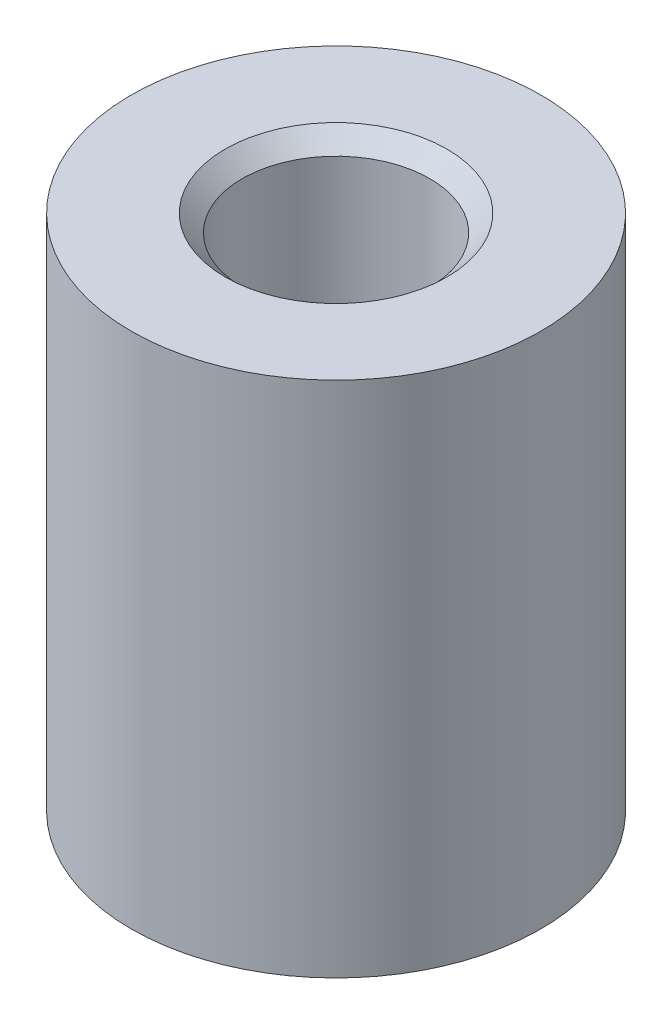
from build123d import *

# Parameters (mm, degrees)
BOSS_EXTRUDE1_DEPTH      = 7.587499938
BOSS_EXTRUDE1_DEPTH_BACK = 7.587499938
SKETCH1_R                = 6
SKETCH1_R_2              = 2
SKETCH2_R                = 2.749999953
CUT_EXTRUDE1_DEPTH       = 18.386219291


with BuildPart() as part:
    # Sketch1 → Boss-Extrude1 (new, two sides: drawn at the far end of the back side and taken through both)
    with BuildSketch(Plane(origin=(0, 0, 0), x_dir=(1, 0, 0), z_dir=(0, 1, 0)).offset(-BOSS_EXTRUDE1_DEPTH_BACK)):
        with Locations(Location((0, 0, 0), (0, 0, 270))):
            Circle(SKETCH1_R)
        with Locations(Location((0, 0, 0), (0, 0, 270))):
            Circle(SKETCH1_R_2, mode=Mode.SUBTRACT)
    extrude(amount=BOSS_EXTRUDE1_DEPTH + BOSS_EXTRUDE1_DEPTH_BACK)

    # Sketch2 → Cut-Extrude1 (cut, through all)
    with BuildSketch(Plane(origin=(0, 7.587499938, 0), x_dir=(1, 0, 0), z_dir=(0, 1, 0))):
        with Locations(Location((0, 0, 0), (0, 0, 270))):
            Circle(SKETCH2_R)
    extrude(amount=-CUT_EXTRUDE1_DEPTH, mode=Mode.SUBTRACT)

    # Cut-Extrude3 cone 1 section (through the dimple's axis) → Cut-Extrude3 (revolve, cut)
    with BuildSketch(Plane(origin=(0, 7.587499938, 0), x_dir=(0, 0, 1), z_dir=(1, 0, 0))):
        Polygon((0, 0), (3.249999953, 0), (0, 3.249999953), align=None)
    cut_extrude3 = revolve(axis=Axis((0, 7.587499938, 0), (0, -1, 0)), mode=Mode.SUBTRACT)

    # Mirror1: Cut-Extrude3 across plane
    add(cut_extrude3.mirror(Plane.ZX), mode=Mode.SUBTRACT)


solid = part.part
